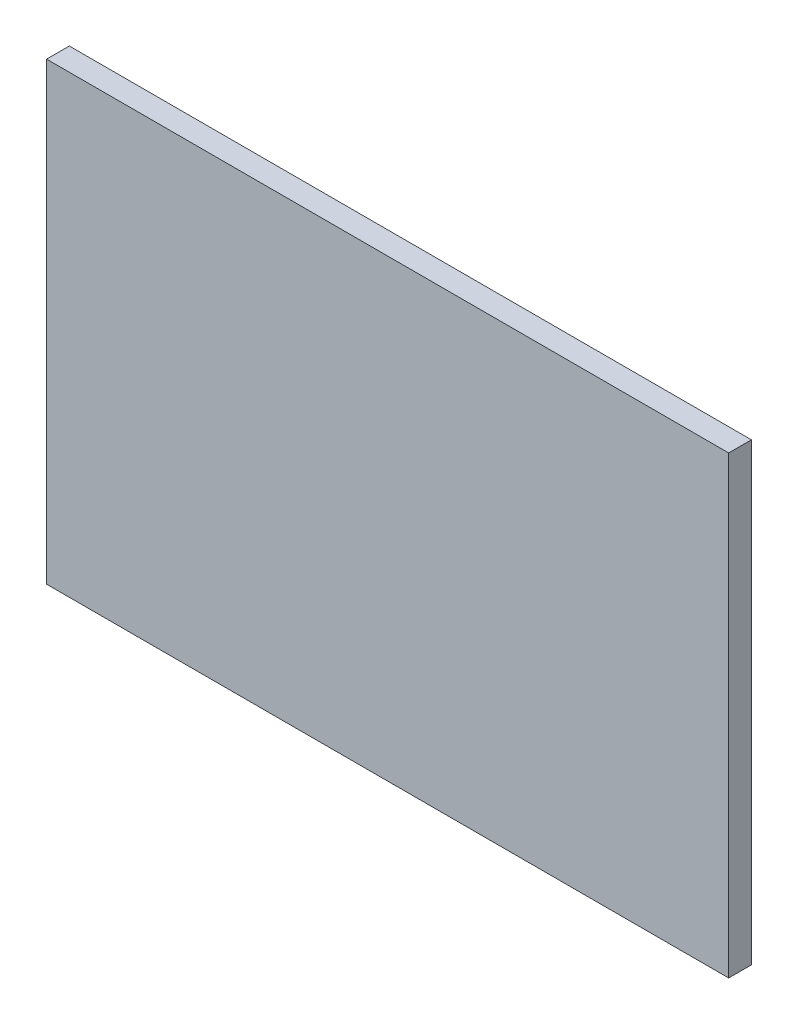
from build123d import *

# Parameters (mm, degrees)
ESQUISSE1_W        = 150
ESQUISSE1_H        = 100
BOSS_EXTRU_1_DEPTH = 5


with BuildPart() as part:
    # Esquisse1 → Boss.-Extru.1 (new body)
    with BuildSketch(Plane.XY):
        with Locations((75, 50)):
            Rectangle(ESQUISSE1_W, ESQUISSE1_H)
    extrude(amount=BOSS_EXTRU_1_DEPTH)


solid = part.part
